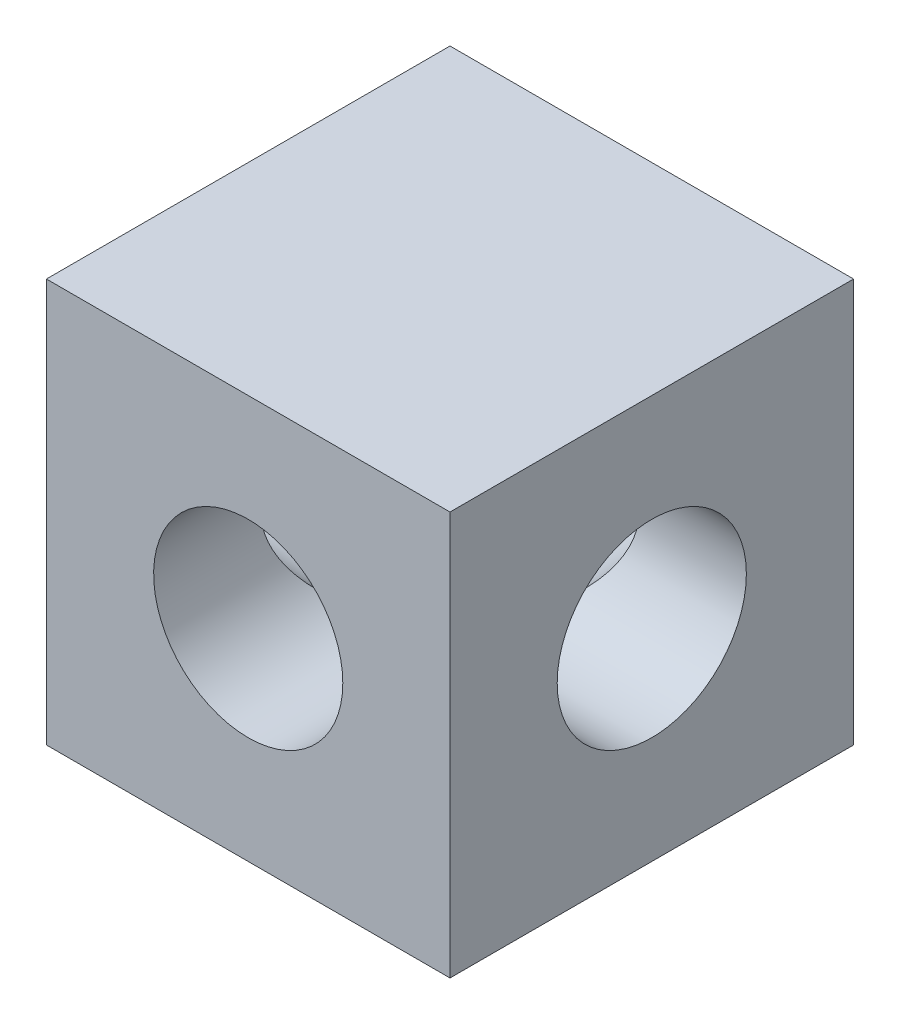
from build123d import *

# Parameters (mm, degrees)
SKETCH1_W          = 20.32
SKETCH1_H          = 20.32
SKETCH1_R          = 4.7625
BASE_EXTRUDE_DEPTH = 10.16
SKETCH3_R          = 4.7625
CUT_EXTRUDE1_DEPTH = 21.32


with BuildPart() as part:
    # Sketch1 → Base-Extrude (new body, symmetric)
    with BuildSketch(Plane.XY):
        Rectangle(SKETCH1_W, SKETCH1_H)
        Circle(SKETCH1_R, mode=Mode.SUBTRACT)
    extrude(amount=BASE_EXTRUDE_DEPTH, both=True)

    # Sketch3 → Cut-Extrude1 (cut, through all)
    with BuildSketch(Plane(origin=(10.16, 0, 0), x_dir=(0, 0, -1), z_dir=(1, 0, 0))):
        Circle(SKETCH3_R)
    extrude(amount=-CUT_EXTRUDE1_DEPTH, mode=Mode.SUBTRACT)


solid = part.part
